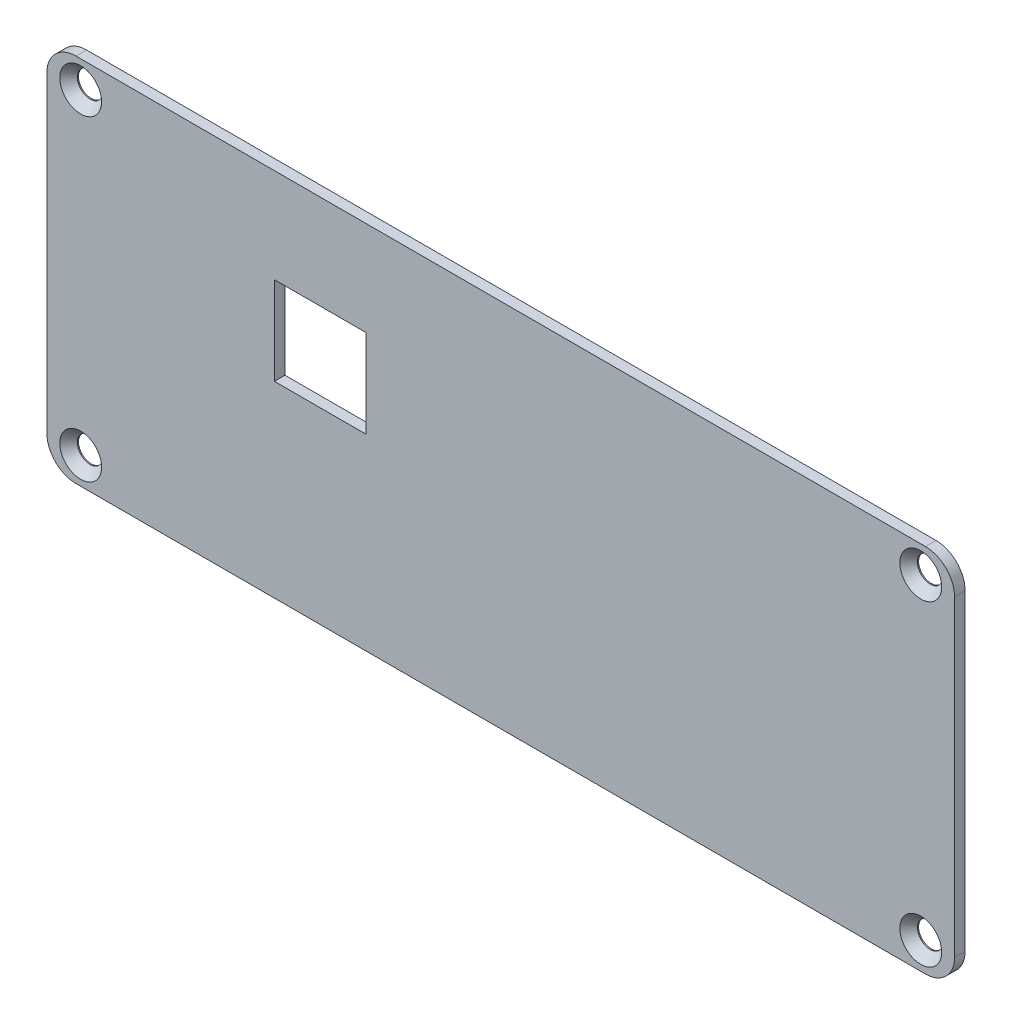
from build123d import *

# Parameters (mm, degrees)
SKETCH1_W                                      = 124.8
SKETCH1_H                                      = 50.9
SKETCH1_W_2                                    = 12.6
SKETCH1_H_2                                    = 12.1
BOSS_EXTRUDE1_DEPTH                            = 1.45
CSK_FOR_M3_5_FLAT_HEAD_MACHINE_SCREW1_AT_COUNT = 2
CSK_FOR_M3_5_FLAT_HEAD_MACHINE_SCREW1_AT_PITCH = 115.5
CSK_FOR_M3_5_FLAT_HEAD_MACHINE_SCREW_2_COUNT   = 2
CSK_FOR_M3_5_FLAT_HEAD_MACHINE_SCREW_2_PITCH   = 123.420014584
CSK_FOR_M3_5_FLAT_HEAD_MACHINE_SCREW_3_COUNT   = 2
CSK_FOR_M3_5_FLAT_HEAD_MACHINE_SCREW_3_PITCH   = 43.5
FILLET2_R                                      = 4


with BuildPart() as part:
    # Sketch1 → Boss-Extrude1 (new body)
    with BuildSketch(Plane.XY):
        with Locations((62.4, -25.45)):
            Rectangle(SKETCH1_W, SKETCH1_H)
        with Locations((37.585, -19.035)):
            Rectangle(SKETCH1_W_2, SKETCH1_H_2, mode=Mode.SUBTRACT)
    extrude(amount=BOSS_EXTRUDE1_DEPTH)

    # Sketch2 → CSK for M3.5 Flat Head Machine Screw1 (revolve, cut)
    with BuildSketch(Plane(origin=(4.65, -3.7, 1.45), x_dir=(0, -1, 0), z_dir=(1, 0, 0))):
        Polygon((0, 0), (0, 1.45), (1.75, 1.45), (1.75, 1.294164458), (2.875, 0), align=None)
    csk_for_m3_5_flat_head_machine_screw1 = revolve(axis=Axis((4.65, -3.7, 7.8), (0, 0, -1)), mode=Mode.SUBTRACT)

    # CSK for M3.5 Flat Head Machine Screw1 at: CSK for M3.5 Flat Head Machine Screw1 ×2
    with Locations(*[(i * CSK_FOR_M3_5_FLAT_HEAD_MACHINE_SCREW1_AT_PITCH, 0, 0) for i in range(1, CSK_FOR_M3_5_FLAT_HEAD_MACHINE_SCREW1_AT_COUNT)]):
        add(csk_for_m3_5_flat_head_machine_screw1, mode=Mode.SUBTRACT)

    # CSK for M3.5 Flat Head Machine Screw 2: CSK for M3.5 Flat Head Machine Screw1 ×2
    with Locations(*[Vector(0.935828766, -0.35245499, 0) * (i * CSK_FOR_M3_5_FLAT_HEAD_MACHINE_SCREW_2_PITCH) for i in range(1, CSK_FOR_M3_5_FLAT_HEAD_MACHINE_SCREW_2_COUNT)]):
        add(csk_for_m3_5_flat_head_machine_screw1, mode=Mode.SUBTRACT)

    # CSK for M3.5 Flat Head Machine Screw 3: CSK for M3.5 Flat Head Machine Screw1 ×2
    with Locations(*[(0, -i * CSK_FOR_M3_5_FLAT_HEAD_MACHINE_SCREW_3_PITCH, 0) for i in range(1, CSK_FOR_M3_5_FLAT_HEAD_MACHINE_SCREW_3_COUNT)]):
        add(csk_for_m3_5_flat_head_machine_screw1, mode=Mode.SUBTRACT)

    # Fillet2
    fillet2_edges = [part.edges().sort_by_distance(p)[0] for p in [
        (124.8, -50.9, 0.725),
        (0, -50.9, 0.725),
        (0, 0, 0.725),
        (124.8, 0, 0.725),
    ]]
    fillet(fillet2_edges, radius=FILLET2_R)


solid = part.part
